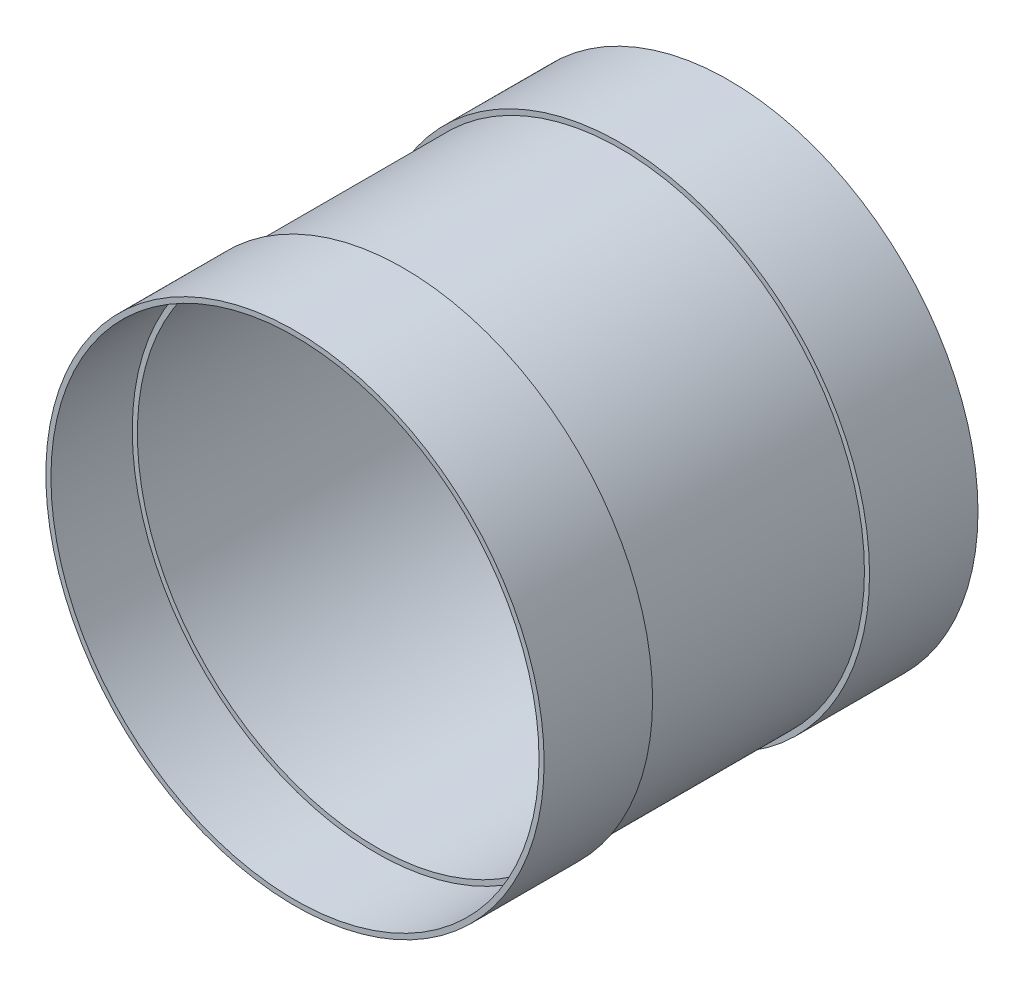
from build123d import *

# Parameters (mm, degrees)
SKETCH2_W = 101.6
SKETCH2_H = 4.7625
SKETCH3_W = 254
SKETCH3_H = 4.7625


with BuildPart() as part:
    # Sketch2 → Revolve1 (revolve)
    with BuildSketch(Plane(origin=(0, 0, 0), x_dir=(0, 0, -1), z_dir=(1, 0, 0)), mode=Mode.PRIVATE) as revolve1_sk:
        with Locations((-152.4, 230.98125)):
            Rectangle(SKETCH2_W, SKETCH2_H)
        with Locations((152.4, 230.98125)):
            Rectangle(SKETCH2_W, SKETCH2_H)
    revolve(revolve1_sk.sketch.rotate(Axis((0, 0, 62.594581749), (0, 0, -1)), 90), axis=Axis((0, 0, 62.594581749), (0, 0, -1)))  # turned: the seam where the file's is


with BuildPart() as body_2:
    # Sketch3 → Revolve2 (revolve)
    with BuildSketch(Plane(origin=(0, 0, 0), x_dir=(0, 0, -1), z_dir=(1, 0, 0)), mode=Mode.PRIVATE) as revolve2_sk:
        with Locations((0, 226.21875)):
            Rectangle(SKETCH3_W, SKETCH3_H)
    revolve(revolve2_sk.sketch.rotate(Axis((0, 0, 0), (0, 0, -1)), 90), axis=Axis((0, 0, 0), (0, 0, -1)))  # turned: the seam where the file's is


solid = Compound([part.part, body_2.part])
